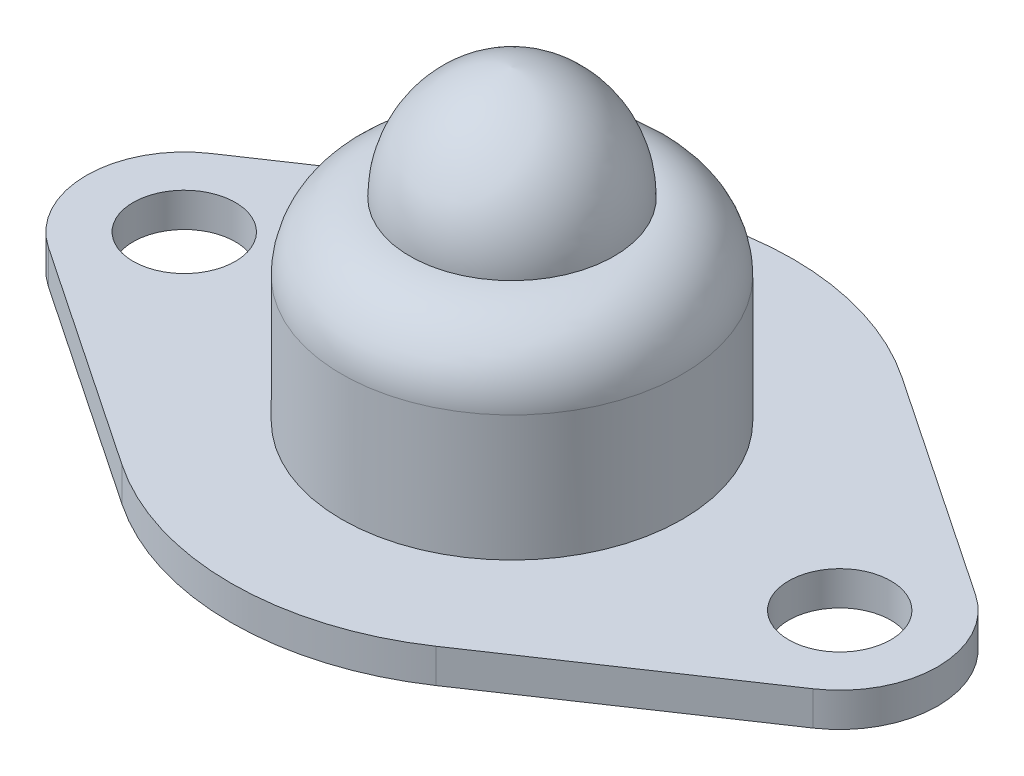
from build123d import *

# Parameters (mm, degrees)
SKETCH2_R          = 1.5
BOSS_EXTRU_1_DEPTH = 1
ESQUISSE1_W        = 5
ESQUISSE1_H        = 3.690231621


with BuildPart() as part:
    # Sketch2 → Boss.-Extru.1 (new body)
    with BuildSketch(Plane(origin=(0, 0, 0), x_dir=(1, 0, 0), z_dir=(0, 1, 0))):
        with BuildLine():
            Line((-4.607142857, 6.843736895), (-11.230519481, 2.384938615))
            ThreePointArc((-11.230519481, 2.384938615), (-12.5, 0), (-11.230519481, -2.384938615))
            Line((-11.230519481, -2.384938615), (-4.607142857, -6.843736895))
            ThreePointArc((-4.607142857, -6.843736895), (0, -8.25), (4.607142857, -6.843736895))
            Line((4.607142857, -6.843736895), (11.230519481, -2.384938615))
            ThreePointArc((11.230519481, -2.384938615), (12.5, 0), (11.230519481, 2.384938615))
            Line((11.230519481, 2.384938615), (4.607142857, 6.843736895))
            ThreePointArc((4.607142857, 6.843736895), (0, 8.25), (-4.607142857, 6.843736895))
        make_face()
        with Locations(Location((-9.625, 0, 0), (0, 0, 270))):
            Circle(SKETCH2_R, mode=Mode.SUBTRACT)
        with Locations(Location((9.625, 0, 0), (0, 0, 270))):
            Circle(SKETCH2_R, mode=Mode.SUBTRACT)
    extrude(amount=BOSS_EXTRU_1_DEPTH)

    # Esquisse1 → Révolution1 (revolve)
    with BuildSketch(Plane.XY, mode=Mode.PRIVATE) as r_volution1_sk:
        with BuildLine():
            ThreePointArc((0, 10), (-2.136216237, 8.92264844), (-2.996693627, 6.690231621))
            Line((-2.996693627, 6.690231621), (0, 6.690231621))
            Line((0, 6.690231621), (0, 10))
        make_face()
        with BuildLine():
            ThreePointArc((-2.996693627, 6.690231621), (-4.413044266, 6.105614645), (-5, 4.690231621))
            Line((-5, 4.690231621), (0, 4.690231621))
            Line((0, 4.690231621), (0, 6.690231621))
            Line((0, 6.690231621), (-2.996693627, 6.690231621))
        make_face()
        with Locations((-2.5, 2.845115811)):
            Rectangle(ESQUISSE1_W, ESQUISSE1_H)
    revolve(r_volution1_sk.sketch.rotate(Axis((0, -1.148221133, 0), (0, 1, 0)), 270), axis=Axis((0, -1.148221133, 0), (0, 1, 0)))


solid = part.part
